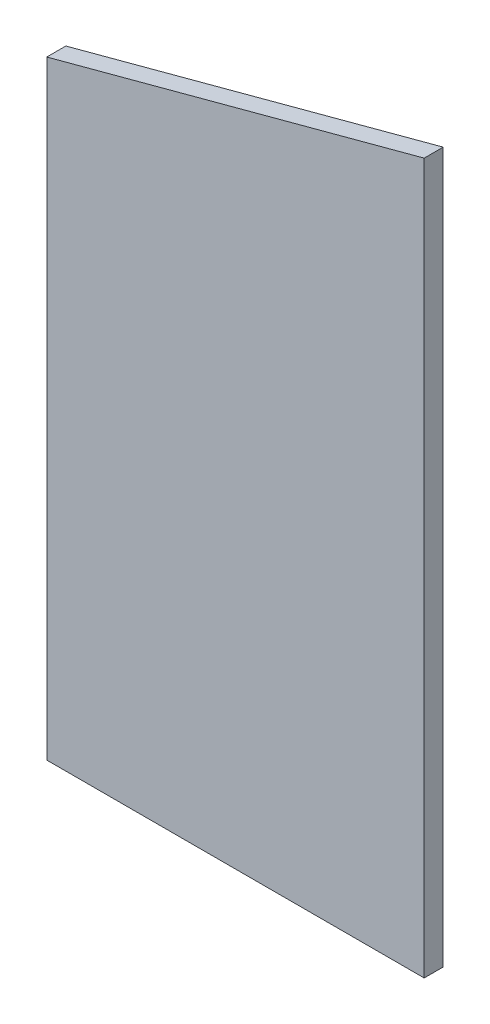
from build123d import *

# Parameters (mm, degrees)
BOSS_EXTRUDE1_DEPTH = 11.90625


with BuildPart() as part:
    # Sketch1 → Boss-Extrude1 (new body)
    with BuildSketch(Plane.XY):
        Polygon((-819.830594651, 11.90625), (-819.830594651, 392.599672186), (-583.900187925, 455.817034138), (-583.900187925, 11.90625), align=None)
    extrude(amount=-BOSS_EXTRUDE1_DEPTH)


solid = part.part
